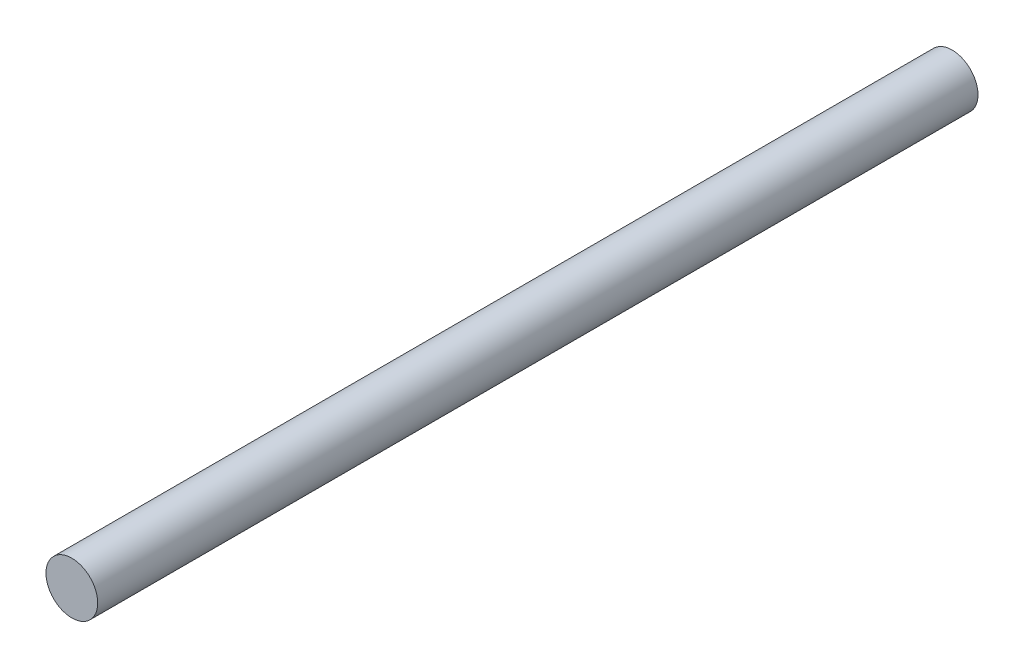
from build123d import *

# Parameters (mm, degrees)
SKETCH1_R           = 5
BOSS_EXTRUDE1_DEPTH = 170


with BuildPart() as part:
    # Sketch1 → Boss-Extrude1 (new body)
    with BuildSketch(Plane.XY):
        Circle(SKETCH1_R)
    extrude(amount=BOSS_EXTRUDE1_DEPTH)


solid = part.part
